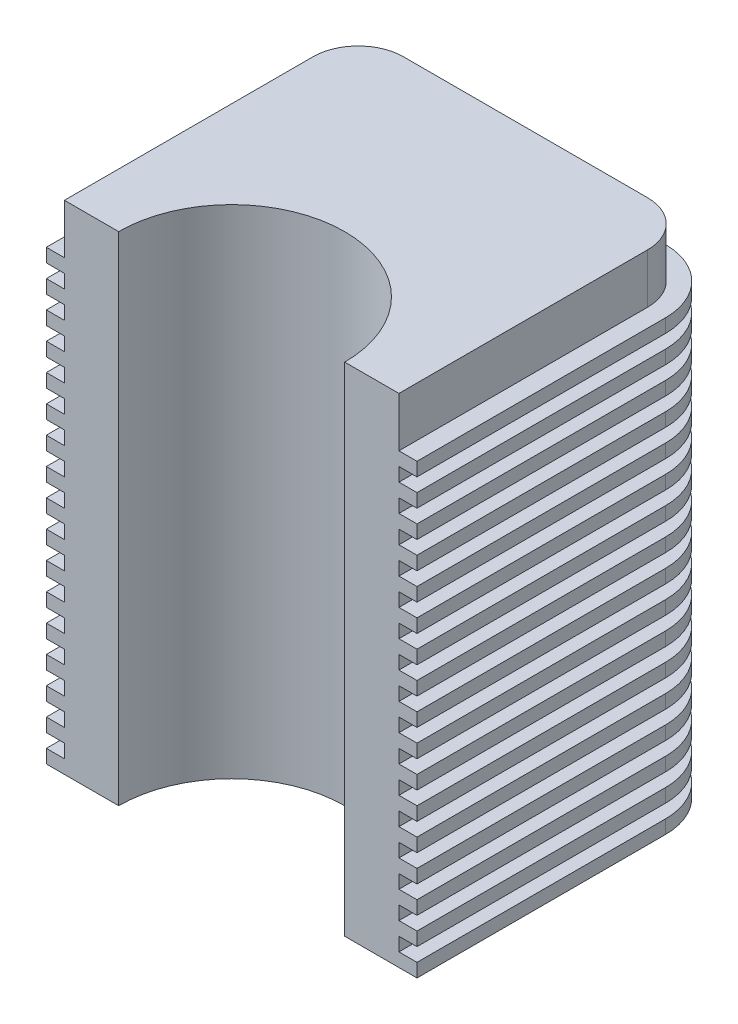
from build123d import *

# Parameters (mm, degrees)
BOSS_EXTRUDE1_DEPTH = 2794
BOSS_EXTRUDE2_DEPTH = 76.2
LPATTERN1_COUNT     = 17
LPATTERN1_PITCH     = 152.4


with BuildPart() as part:
    # Sketch1 → Boss-Extrude1 (new body)
    with BuildSketch(Plane(origin=(0, 0, 0), x_dir=(1, 0, 0), z_dir=(0, 1, 0))):
        with BuildLine():
            Line((635, 0), (939.8, 0))
            Line((939.8, 0), (939.8, 1397))
            ThreePointArc((939.8, 1397), (865.405122421, 1576.605122421), (685.8, 1651))
            Line((685.8, 1651), (-685.8, 1651))
            ThreePointArc((-685.8, 1651), (-865.405122421, 1576.605122421), (-939.8, 1397))
            Line((-939.8, 1397), (-939.8, 0))
            Line((-939.8, 0), (-635, 0))
            ThreePointArc((-635, 0), (0, 635), (635, 0))
        make_face()
    extrude(amount=BOSS_EXTRUDE1_DEPTH)

    # Sketch2 → Boss-Extrude2 (add)
    with BuildSketch(Plane.XZ):
        with BuildLine():
            Line((-1041.4, 0), (-1041.4, -1397))
            ThreePointArc((-1041.4, -1397), (-937.24717139, -1648.44717139), (-685.8, -1752.6))
            Line((-685.8, -1752.6), (685.8, -1752.6))
            ThreePointArc((685.8, -1752.6), (937.24717139, -1648.44717139), (1041.4, -1397))
            Line((1041.4, -1397), (1041.4, 0))
            Line((1041.4, 0), (939.8, 0))
            Line((939.8, 0), (939.8, -1397))
            ThreePointArc((939.8, -1397), (865.405122421, -1576.605122421), (685.8, -1651))
            Line((685.8, -1651), (-685.8, -1651))
            ThreePointArc((-685.8, -1651), (-865.405122421, -1576.605122421), (-939.8, -1397))
            Line((-939.8, -1397), (-939.8, 0))
            Line((-939.8, 0), (-1041.4, 0))
        make_face()
    boss_extrude2 = extrude(amount=-BOSS_EXTRUDE2_DEPTH)

    # LPattern1: Boss-Extrude2 ×17
    with Locations(*[(0, i * LPATTERN1_PITCH, 0) for i in range(1, LPATTERN1_COUNT)]):
        add(boss_extrude2)


solid = part.part
